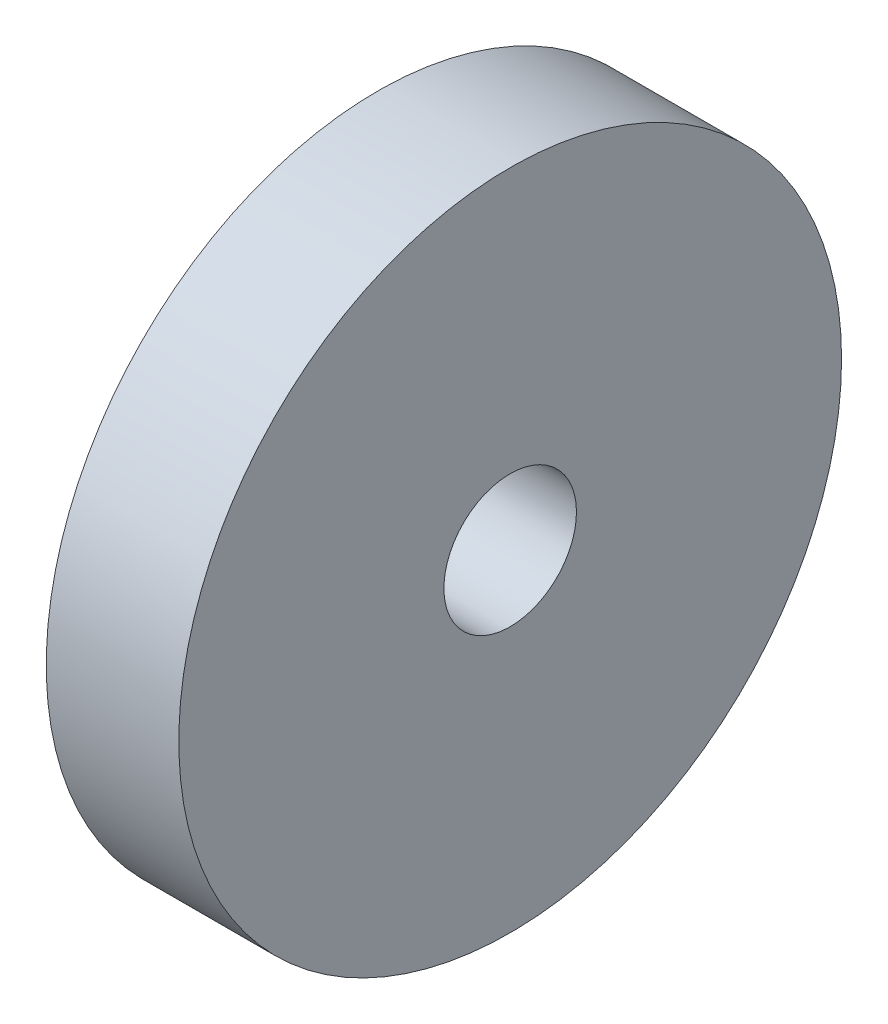
from build123d import *

# Parameters (mm, degrees)
SKETCH1_R           = 7.5
BOSS_EXTRUDE1_DEPTH = 3
SKETCH2_R           = 1.5
CUT_EXTRUDE1_DEPTH  = 4


with BuildPart() as part:
    # Sketch1 → Boss-Extrude1 (new body)
    with BuildSketch(Plane(origin=(0, 0, 0), x_dir=(0, 0, -1), z_dir=(1, 0, 0))):
        Circle(SKETCH1_R)
    extrude(amount=BOSS_EXTRUDE1_DEPTH)

    # Sketch2 → Cut-Extrude1 (cut, through all)
    with BuildSketch(Plane(origin=(3, 0, 0), x_dir=(0, 0, -1), z_dir=(1, 0, 0))):
        Circle(SKETCH2_R)
    extrude(amount=-CUT_EXTRUDE1_DEPTH, mode=Mode.SUBTRACT)


solid = part.part
